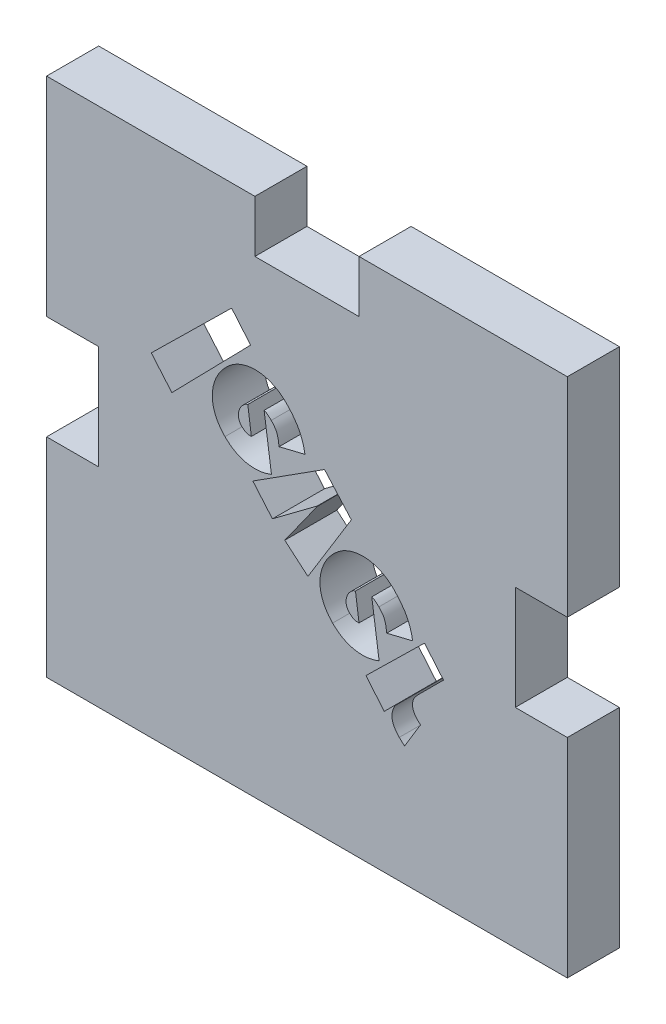
from build123d import *

# Parameters (mm, degrees)
EXTRUDE1_DEPTH     = 3.175
CUT_EXTRUDE1_DEPTH = 4.175


with BuildPart() as part:
    # Sketch1 → Extrude1 (new body)
    with BuildSketch(Plane.XY):
        Polygon((-15.875, 15.875), (-3.175, 15.875), (-3.175, 12.7), (3.175, 12.7), (3.175, 15.875), (15.875, 15.875), (15.875, 3.175), (12.7, 3.175), (12.7, -3.175), (15.875, -3.175), (15.875, -15.875), (3.175, -15.875), (-3.175, -15.875), (-15.875, -15.875), (-15.875, -3.175), (-12.7, -3.175), (-12.7, 3.175), (-15.875, 3.175), align=None)
    extrude(amount=EXTRUDE1_DEPTH)

    # Sketch2 → Cut-Extrude1 (cut, through all)
    with BuildSketch(Plane.XY.offset(3.175)):
        Polygon((-4.594790239, 9.263620483), (-3.436744201, 7.887355918), (-8.236311884, 2.978678973), (-9.492308283, 4.450414142), align=None)
        with BuildLine():
            Line((-0.122358551, 3.776968601), (-1.701963104, 3.39012667))
            add(Edge.make_bspline(
                [(-1.701963104, 3.39012667), (-1.711447603, 3.488877015), (-1.730478435, 3.687021516), (-1.792451714, 3.930533566), (-1.864341974, 4.124215415), (-1.946492337, 4.267250227), (-2.050732987, 4.409693874), (-2.134420587, 4.497440264), (-2.178076251, 4.543213197)],
                knots=[0, 0, 0, 0, 0.000297274, 0.000596485, 0.000750754, 0.000915621, 0.00108946, 0.001279036, 0.001279036, 0.001279036, 0.001279036], degree=3))
            add(Edge.make_bspline(
                [(-2.178076251, 4.543213197), (-2.210322685, 4.574284566), (-2.278118209, 4.639609609), (-2.387736765, 4.727812258), (-2.495176683, 4.811512738), (-2.575651516, 4.841916948), (-2.612033546, 4.855662449)],
                knots=[0, 0, 0, 0, 0.000134211, 0.000282167, 0.000422848, 0.000538928, 0.000538928, 0.000538928, 0.000538928], degree=3))
            Line((-2.612033546, 4.855662449), (-2.165677471, 1.696453341))
            add(Edge.make_bspline(
                [(-2.165677471, 1.696453341), (-2.226585233, 1.673404237), (-2.347186197, 1.62776565), (-2.53086213, 1.572750561), (-2.715522249, 1.533481882), (-2.900564319, 1.505622357), (-3.086664531, 1.492109733), (-3.273545023, 1.49210667), (-3.460861439, 1.505766007), (-3.647688602, 1.533200379), (-3.83309732, 1.573168399), (-4.013497436, 1.63153232), (-4.19112678, 1.699906337), (-4.362096362, 1.787128239), (-4.530690838, 1.885551184), (-4.691956798, 2.002165199), (-4.851544558, 2.129355393), (-4.949992604, 2.225408171), (-5.000038547, 2.274236483)],
                knots=[0, 0, 0, 0, 0.000195335, 0.000386775, 0.000574517, 0.000761262, 0.000947743, 0.001133724, 0.001321442, 0.00151064, 0.001699859, 0.001889653, 0.002078913, 0.002270212, 0.002464778, 0.00266397, 0.002866712, 0.003076339, 0.003076339, 0.003076339, 0.003076339], degree=3))
            add(Edge.make_bspline(
                [(-5.000038547, 2.274236483), (-5.059971982, 2.337210519), (-5.178696821, 2.461958621), (-5.333373459, 2.666400026), (-5.466963012, 2.880363028), (-5.577797786, 3.104090083), (-5.664370404, 3.335549984), (-5.727089295, 3.572682398), (-5.764284001, 3.814544798), (-5.776884019, 4.060513821), (-5.763052338, 4.30902912), (-5.722876472, 4.558663181), (-5.656323263, 4.808887527), (-5.564669219, 5.059699139), (-5.444902359, 5.308484516), (-5.291024044, 5.549650118), (-5.110261085, 5.786715684), (-4.97010634, 5.933577959), (-4.898368552, 6.008748976)],
                knots=[0, 0, 0, 0, 0.000260637, 0.000516308, 0.000767465, 0.001016433, 0.001264003, 0.0015076, 0.001750995, 0.001996804, 0.002245154, 0.002496284, 0.002754018, 0.00302075, 0.003296352, 0.003580498, 0.003877593, 0.004189108, 0.004189108, 0.004189108, 0.004189108], degree=3))
            add(Edge.make_bspline(
                [(-4.898368552, 6.008748976), (-4.837125824, 6.066728062), (-4.715746449, 6.181639096), (-4.514245987, 6.329157825), (-4.301352205, 6.455325429), (-4.077175737, 6.557961983), (-3.844715959, 6.636953999), (-3.60832174, 6.694683195), (-3.367698474, 6.726966636), (-3.124795246, 6.73540858), (-2.880099745, 6.720946763), (-2.636068025, 6.680492907), (-2.392773622, 6.616845264), (-2.151366035, 6.528961431), (-1.914512452, 6.416015088), (-1.684578495, 6.278065773), (-1.465803787, 6.110813076), (-1.330550774, 5.983133119), (-1.261806419, 5.918237883)],
                knots=[0, 0, 0, 0, 0.000252795, 0.000501025, 0.000747265, 0.000994153, 0.001239213, 0.001482801, 0.001723031, 0.001966202, 0.00221091, 0.002457144, 0.002707052, 0.002964356, 0.003226678, 0.003493113, 0.003767381, 0.004050869, 0.004050869, 0.004050869, 0.004050869], degree=3))
            add(Edge.make_bspline(
                [(-1.261806419, 5.918237883), (-1.182103841, 5.835824067), (-1.026851928, 5.675290959), (-0.819789555, 5.423163986), (-0.641323124, 5.170918955), (-0.490141574, 4.916230489), (-0.363754167, 4.652974945), (-0.262193707, 4.375620572), (-0.176790167, 4.083137988), (-0.140729512, 3.880302407), (-0.122358551, 3.776968601)],
                knots=[0, 0, 0, 0, 0.000343838, 0.000669758, 0.000977633, 0.001270015, 0.001557285, 0.001852308, 0.00215529, 0.002469941, 0.002469941, 0.002469941, 0.002469941], degree=3))
        make_face()
        with BuildLine():
            Line((-3.389437043, 3.088836319), (-3.607655569, 4.668440873))
            add(Edge.make_bspline(
                [(-3.607655569, 4.668440873), (-3.630923553, 4.660531534), (-3.676601418, 4.645004544), (-3.732422308, 4.620217149), (-3.77745527, 4.592446885), (-3.816201744, 4.562718204), (-3.861655614, 4.523733602), (-3.892232005, 4.493038558), (-3.908945919, 4.476259785)],
                knots=[0, 0, 0, 0, 7.3728e-05, 0.000144738, 0.00018259, 0.000232185, 0.000291089, 0.000362109, 0.000362109, 0.000362109, 0.000362109], degree=3))
            add(Edge.make_bspline(
                [(-3.908945919, 4.476259785), (-3.945348058, 4.436612537), (-4.018299961, 4.357157255), (-4.097062145, 4.215409029), (-4.154135223, 4.064787452), (-4.182926578, 3.907144109), (-4.181640569, 3.748222152), (-4.156212681, 3.618223636), (-4.11586435, 3.521111348), (-4.078813523, 3.450563389), (-4.03126611, 3.384578303), (-3.993722277, 3.344674323), (-3.974659452, 3.324413137)],
                knots=[0, 0, 0, 0, 0.000160979, 0.000322611, 0.000482675, 0.000642701, 0.00080017, 0.000957259, 0.001036232, 0.001115001, 0.00119586, 0.001279264, 0.001279264, 0.001279264, 0.001279264], degree=3))
            add(Edge.make_bspline(
                [(-3.974659452, 3.324413137), (-3.932860366, 3.286224225), (-3.852988715, 3.213251065), (-3.73859484, 3.142306926), (-3.641356585, 3.106600884), (-3.563078736, 3.089027318), (-3.477887088, 3.083171069), (-3.41959149, 3.086904919), (-3.389437043, 3.088836319)],
                knots=[0, 0, 0, 0, 0.000169718, 0.000324306, 0.000399623, 0.000479641, 0.00056418, 0.000654767, 0.000654767, 0.000654767, 0.000654767], degree=3))
        make_face(mode=Mode.SUBTRACT)
        Polygon((-3.300414166, 0.780431848), (1.071395612, 3.572637072), (2.705554797, 1.732658141), (0.058415297, -2.578397616), (-1.35256585, -1.373236214), (0.631238927, 1.40657023), (0.618840147, 1.41896901), (-2.106411666, -0.619390398), align=None)
        with BuildLine():
            Line((6.442566723, -2.787956672), (4.862962169, -3.174798604))
            add(Edge.make_bspline(
                [(4.862962169, -3.174798604), (4.853477671, -3.076048259), (4.834446839, -2.877903758), (4.772473559, -2.634391708), (4.700583299, -2.440709858), (4.618432937, -2.297675046), (4.514192287, -2.155231399), (4.430504687, -2.06748501), (4.386849022, -2.021712077)],
                knots=[0, 0, 0, 0, 0.000297274, 0.000596485, 0.000750754, 0.000915621, 0.00108946, 0.001279036, 0.001279036, 0.001279036, 0.001279036], degree=3))
            add(Edge.make_bspline(
                [(4.386849022, -2.021712077), (4.354602588, -1.990640708), (4.286807064, -1.925315664), (4.177188509, -1.837113016), (4.069748591, -1.753412536), (3.989273757, -1.723008325), (3.952891727, -1.709262824)],
                knots=[0, 0, 0, 0, 0.000134211, 0.000282167, 0.000422848, 0.000538928, 0.000538928, 0.000538928, 0.000538928], degree=3))
            Line((3.952891727, -1.709262824), (4.399247802, -4.868471932))
            add(Edge.make_bspline(
                [(4.399247802, -4.868471932), (4.33834004, -4.891521037), (4.217739076, -4.937159624), (4.034063144, -4.992174713), (3.849403024, -5.031443391), (3.664360955, -5.059302917), (3.478260743, -5.07281554), (3.29138025, -5.072818604), (3.104063834, -5.059159266), (2.917236672, -5.031724894), (2.731827953, -4.991756874), (2.551427837, -4.933392954), (2.373798494, -4.865018936), (2.202828911, -4.777797034), (2.034234436, -4.67937409), (1.872968475, -4.562760074), (1.713380715, -4.435569881), (1.614932669, -4.339517102), (1.564886727, -4.290688791)],
                knots=[0, 0, 0, 0, 0.000195335, 0.000386775, 0.000574517, 0.000761262, 0.000947743, 0.001133724, 0.001321442, 0.00151064, 0.001699859, 0.001889653, 0.002078913, 0.002270212, 0.002464778, 0.00266397, 0.002866712, 0.003076339, 0.003076339, 0.003076339, 0.003076339], degree=3))
            add(Edge.make_bspline(
                [(1.564886727, -4.290688791), (1.504953291, -4.227714754), (1.386228452, -4.102966652), (1.231551814, -3.898525247), (1.097962261, -3.684562245), (0.987127488, -3.46083519), (0.90055487, -3.22937529), (0.837835979, -2.992242876), (0.800641272, -2.750380476), (0.788041254, -2.504411452), (0.801872935, -2.255896154), (0.842048802, -2.006262092), (0.908602011, -1.756037747), (1.000256054, -1.505226135), (1.120022914, -1.256440758), (1.27390123, -1.015275156), (1.454664189, -0.778209589), (1.594818934, -0.631347315), (1.666556722, -0.556176298)],
                knots=[0, 0, 0, 0, 0.000260637, 0.000516308, 0.000767465, 0.001016433, 0.001264003, 0.0015076, 0.001750995, 0.001996804, 0.002245154, 0.002496284, 0.002754018, 0.00302075, 0.003296352, 0.003580498, 0.003877593, 0.004189108, 0.004189108, 0.004189108, 0.004189108], degree=3))
            add(Edge.make_bspline(
                [(1.666556722, -0.556176298), (1.72779945, -0.498197212), (1.849178825, -0.383286177), (2.050679287, -0.235767448), (2.263573069, -0.109599845), (2.487749537, -0.006963291), (2.720209314, 0.072028726), (2.956603534, 0.129757922), (3.197226799, 0.162041363), (3.440130027, 0.170483307), (3.684825529, 0.15602149), (3.928857249, 0.115567634), (4.172151651, 0.05191999), (4.413559239, -0.035963842), (4.650412822, -0.148910185), (4.880346779, -0.2868595), (5.099121487, -0.454112197), (5.2343745, -0.581792155), (5.303118854, -0.646687391)],
                knots=[0, 0, 0, 0, 0.000252795, 0.000501025, 0.000747265, 0.000994153, 0.001239213, 0.001482801, 0.001723031, 0.001966202, 0.00221091, 0.002457144, 0.002707052, 0.002964356, 0.003226678, 0.003493113, 0.003767381, 0.004050869, 0.004050869, 0.004050869, 0.004050869], degree=3))
            add(Edge.make_bspline(
                [(5.303118854, -0.646687391), (5.382821432, -0.729101207), (5.538073345, -0.889634314), (5.745135719, -1.141761288), (5.92360215, -1.394006318), (6.074783699, -1.648694785), (6.201171107, -1.911950329), (6.302731567, -2.189304702), (6.388135107, -2.481787285), (6.424195761, -2.684622866), (6.442566723, -2.787956672)],
                knots=[0, 0, 0, 0, 0.000343838, 0.000669758, 0.000977633, 0.001270015, 0.001557285, 0.001852308, 0.00215529, 0.002469941, 0.002469941, 0.002469941, 0.002469941], degree=3))
        make_face()
        with BuildLine():
            Line((3.17548823, -3.476088954), (2.957269705, -1.8964844))
            add(Edge.make_bspline(
                [(2.957269705, -1.8964844), (2.934001721, -1.90439374), (2.888323855, -1.919920729), (2.832502965, -1.944708124), (2.787470003, -1.972478388), (2.748723529, -2.00220707), (2.703269659, -2.041191672), (2.672693268, -2.071886715), (2.655979354, -2.088665488)],
                knots=[0, 0, 0, 0, 7.3728e-05, 0.000144738, 0.00018259, 0.000232185, 0.000291089, 0.000362109, 0.000362109, 0.000362109, 0.000362109], degree=3))
            add(Edge.make_bspline(
                [(2.655979354, -2.088665488), (2.619577215, -2.128312737), (2.546625313, -2.207768019), (2.467863128, -2.349516244), (2.41079005, -2.500137821), (2.381998696, -2.657781165), (2.383284704, -2.816703121), (2.408712593, -2.946701637), (2.449060923, -3.043813926), (2.48611175, -3.114361885), (2.533659164, -3.180346971), (2.571202996, -3.220250951), (2.590265821, -3.240512137)],
                knots=[0, 0, 0, 0, 0.000160979, 0.000322611, 0.000482675, 0.000642701, 0.00080017, 0.000957259, 0.001036232, 0.001115001, 0.00119586, 0.001279264, 0.001279264, 0.001279264, 0.001279264], degree=3))
            add(Edge.make_bspline(
                [(2.590265821, -3.240512137), (2.632064908, -3.278701049), (2.711936559, -3.351674209), (2.826330433, -3.422618347), (2.923568689, -3.45832439), (3.001846537, -3.475897955), (3.087038186, -3.481754204), (3.145333784, -3.478020355), (3.17548823, -3.476088954)],
                knots=[0, 0, 0, 0, 0.000169718, 0.000324306, 0.000399623, 0.000479641, 0.00056418, 0.000654767, 0.000654767, 0.000654767, 0.000654767], degree=3))
        make_face(mode=Mode.SUBTRACT)
        with BuildLine():
            Line((3.59555853, -6.043627925), (7.166407129, -2.547172005))
            Line((7.166407129, -2.547172005), (8.324453167, -3.920956813))
            Line((8.324453167, -3.920956813), (6.774605685, -5.470804295))
            add(Edge.make_bspline(
                [(6.774605685, -5.470804295), (6.746565838, -5.500234357), (6.6923885, -5.557097806), (6.619233118, -5.645185056), (6.560278177, -5.734798836), (6.510663884, -5.822885279), (6.474566576, -5.911755859), (6.449482748, -6.000291288), (6.435075213, -6.088983075), (6.434580173, -6.20506564), (6.454034567, -6.345755948), (6.508534962, -6.505054674), (6.592245264, -6.652959783), (6.668719936, -6.737219723), (6.707652274, -6.780115448)],
                knots=[0, 0, 0, 0, 0.000121944, 0.000235614, 0.000342905, 0.000443343, 0.000538434, 0.000629891, 0.000718973, 0.000807013, 0.000977274, 0.001142346, 0.001309513, 0.00148287, 0.00148287, 0.00148287, 0.00148287], degree=3))
            add(Edge.make_bspline(
                [(6.707652274, -6.780115448), (6.730796663, -6.803259838), (6.770886051, -6.843349226), (6.810975439, -6.883438614), (6.827920439, -6.900383613)],
                knots=[0, 0, 0, 0, 9.8193e-05, 0.000170085, 0.000170085, 0.000170085, 0.000170085], degree=3))
            add(Edge.make_bspline(
                [(6.827920439, -6.900383613), (6.843823657, -6.91550936), (6.874842826, -6.945012075), (6.908318091, -6.971693292), (6.924630922, -6.984695316)],
                knots=[0, 0, 0, 0, 6.5807e-05, 0.000128356, 0.000128356, 0.000128356, 0.000128356], degree=3))
            Line((6.924630922, -6.984695316), (5.953806459, -8.58289804))
            add(Edge.make_bspline(
                [(5.953806459, -8.58289804), (5.898479412, -8.538722564), (5.784854135, -8.447999292), (5.681002284, -8.346224512), (5.627718548, -8.294006469)],
                knots=[0, 0, 0, 0, 0.000212251, 0.0004359, 0.0004359, 0.0004359, 0.0004359], degree=3))
            add(Edge.make_bspline(
                [(5.627718548, -8.294006469), (5.598064073, -8.262882589), (5.540080067, -8.202025424), (5.460554927, -8.108294409), (5.391394792, -8.012904447), (5.332676496, -7.916892669), (5.281611745, -7.821076102), (5.243631337, -7.723345808), (5.213409889, -7.625689809), (5.193351877, -7.526851887), (5.183455796, -7.427581393), (5.183383584, -7.32788574), (5.193694205, -7.2274408), (5.213267064, -7.126502644), (5.24358454, -7.024926218), (5.284007165, -6.923432493), (5.33147198, -6.819693629), (5.37162069, -6.753297963), (5.392141731, -6.719361427)],
                knots=[0, 0, 0, 0, 0.000128953, 0.000252145, 0.000368462, 0.000482018, 0.000589602, 0.00069367, 0.000796041, 0.00089598, 0.000995665, 0.001094855, 0.00119454, 0.001298128, 0.001402874, 0.001512011, 0.001625715, 0.001744595, 0.001744595, 0.001744595, 0.001744595], degree=3))
            Line((5.392141731, -6.719361427), (5.380982829, -6.708202525))
            Line((5.380982829, -6.708202525), (4.711448717, -7.377736638))
            Line((4.711448717, -7.377736638), (3.59555853, -6.043627925))
        make_face()
    extrude(amount=-CUT_EXTRUDE1_DEPTH, mode=Mode.SUBTRACT)


solid = part.part
